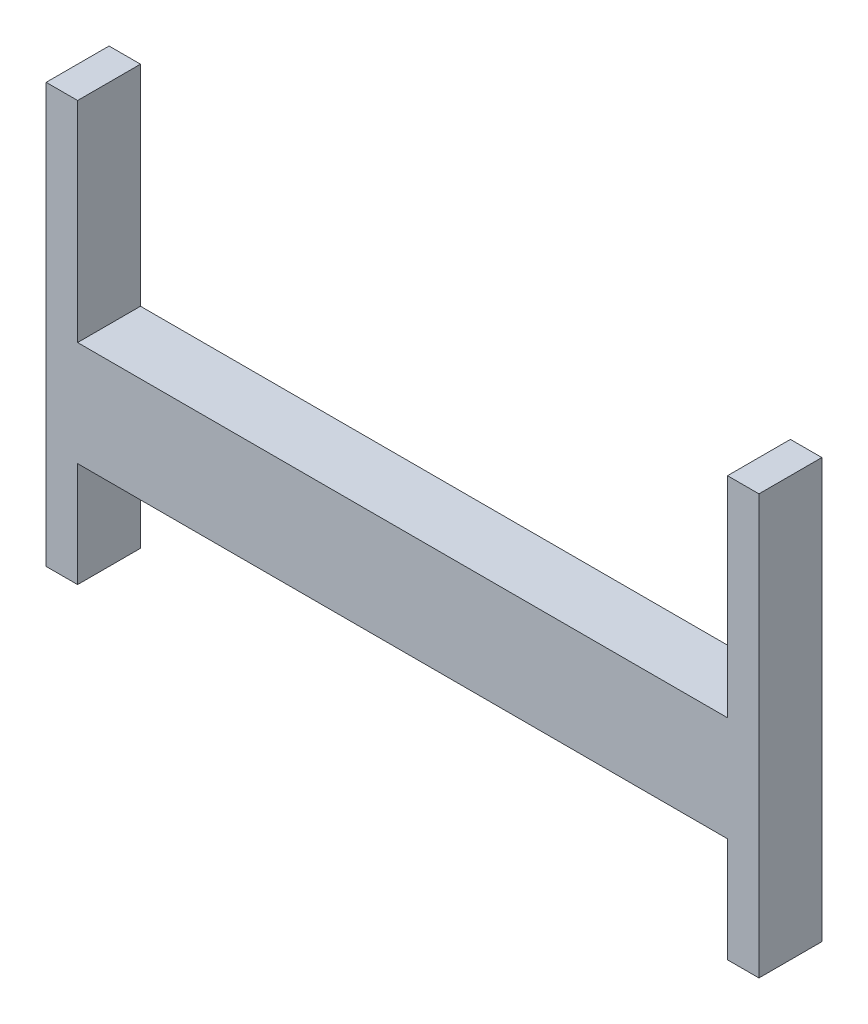
from build123d import *

# Parameters (mm, degrees)
SALIENTE_EXTRUIR1_DEPTH = 30


with BuildPart() as part:
    # Croquis1 → Saliente-Extruir1 (new body)
    with BuildSketch(Plane.XY):
        Polygon((155, -25), (-155, -25), (-155, -75), (-170, -75), (-170, -25), (-170, 125), (-155, 125), (-155, 25), (155, 25), (155, 125), (170, 125), (170, -25), (170, -75), (155, -75), align=None)
    extrude(amount=SALIENTE_EXTRUIR1_DEPTH)


solid = part.part
